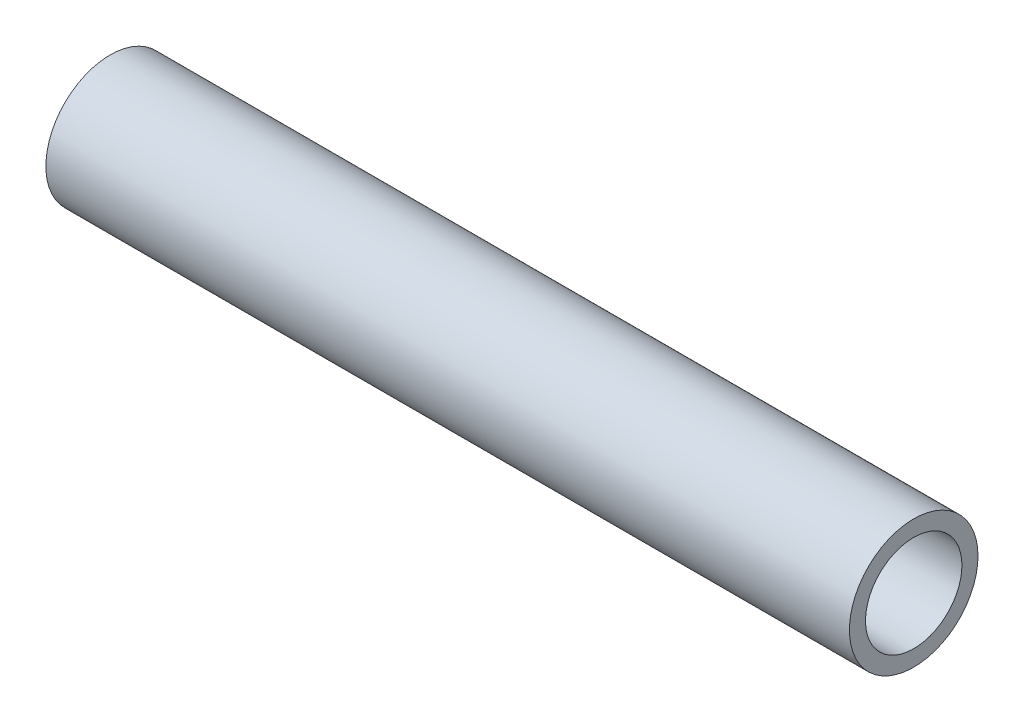
from build123d import *

# Parameters (mm, degrees)
SKETCH1_R           = 2
SKETCH1_R_2         = 1.5
BOSS_EXTRUDE1_DEPTH = 25


with BuildPart() as part:
    # Sketch1 → Boss-Extrude1 (new body)
    with BuildSketch(Plane(origin=(0, 0, 0), x_dir=(0, 0, -1), z_dir=(1, 0, 0))):
        Circle(SKETCH1_R)
        Circle(SKETCH1_R_2, mode=Mode.SUBTRACT)
    extrude(amount=BOSS_EXTRUDE1_DEPTH)


solid = part.part
